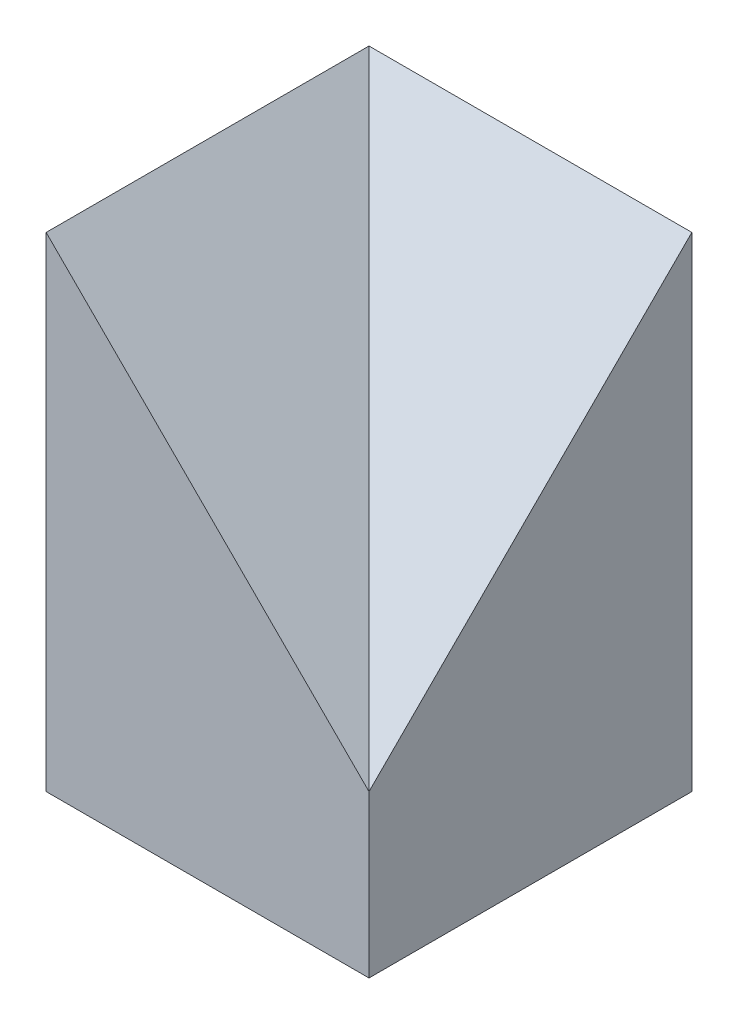
from build123d import *

# Parameters (mm, degrees)
SKIZZE1_W                       = 400
SKIZZE1_H                       = 400
AUFSATZ_LINEAR_AUSTRAGEN1_DEPTH = 200
SKIZZE2_W                       = 400
SKIZZE2_H                       = 400
AUFSATZ_LINEAR_AUSTRAGEN2_DEPTH = 400
SKIZZE3_W                       = 400
SKIZZE3_H                       = 400
SCHNITT_LINEAR_AUSTRAGEN1_DEPTH = 1040.962535349


with BuildPart() as part:
    # Skizze1 → Aufsatz-Linear austragen1 (new body)
    with BuildSketch(Plane(origin=(0, 0, 0), x_dir=(1, 0, 0), z_dir=(0, 1, 0))):
        with Locations((200, -200)):
            Rectangle(SKIZZE1_W, SKIZZE1_H)
    extrude(amount=AUFSATZ_LINEAR_AUSTRAGEN1_DEPTH)

    # Skizze2 → Aufsatz-Linear austragen2 (add)
    with BuildSketch(Plane(origin=(0, 200, 0), x_dir=(1, 0, 0), z_dir=(0, 1, 0))):
        with Locations((200, -200)):
            Rectangle(SKIZZE2_W, SKIZZE2_H)
    extrude(amount=AUFSATZ_LINEAR_AUSTRAGEN2_DEPTH)

    # Skizze3 → Schnitt-Linear austragen1 (cut, through all, along a direction that is not the sketch's normal)
    with BuildSketch(Plane(origin=(0, 600, 0), x_dir=(1, 0, 0), z_dir=(0, 1, 0))):
        with Locations((200, -200)):
            Rectangle(SKIZZE3_W, SKIZZE3_H)
    extrude(amount=-SCHNITT_LINEAR_AUSTRAGEN1_DEPTH, dir=(-0.577350269, 0.577350269, -0.577350269), mode=Mode.SUBTRACT)


solid = part.part
